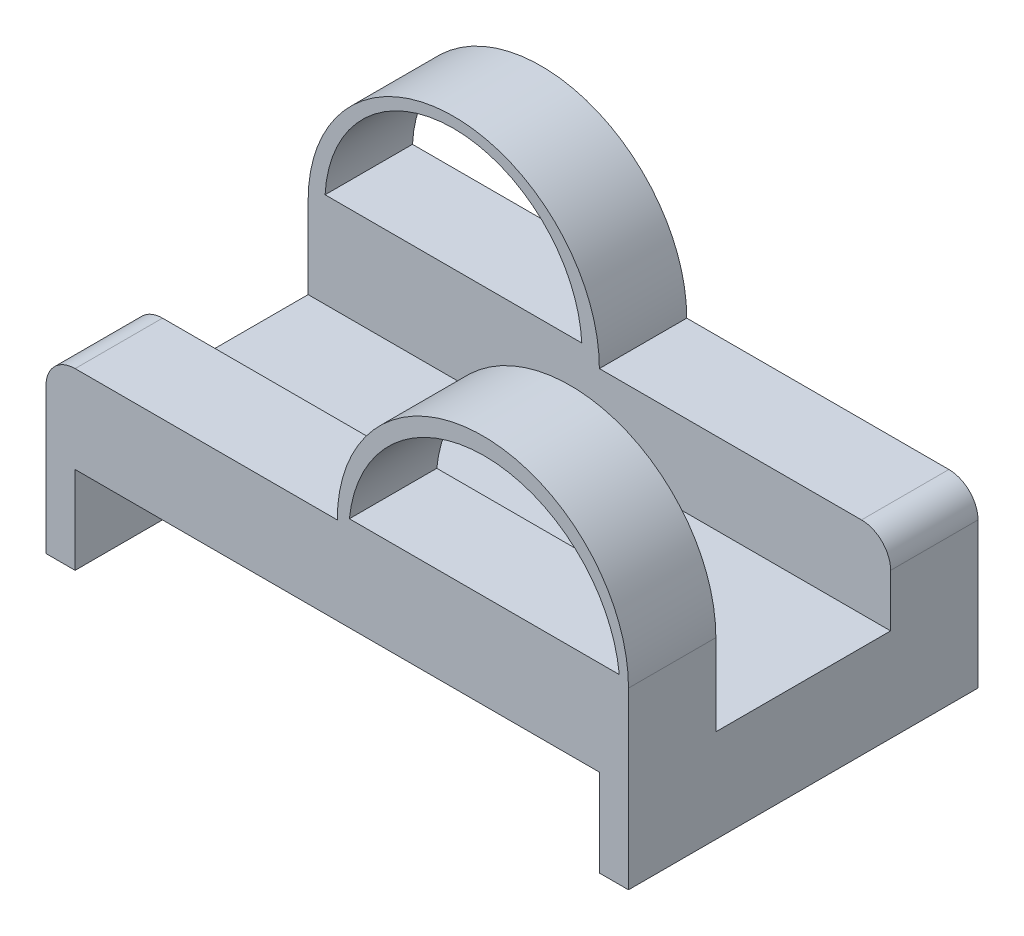
from build123d import *

# Parameters (mm, degrees)
BOSS_EXTRUDE1_DEPTH  = 60
BOSS_EXTRUDE2_DEPTH  = 15
BOSS_EXTRUDE4_DEPTH  = 15
CUT_EXTRUDE3_DEPTH   = 25
CUT_EXTRUDE4_DEPTH   = 25
FILLET2_R            = 5
FILLET3_R            = 5
SKETCH10_W           = 100
SKETCH10_H           = 30
CUT_EXTRUDE8_DEPTH   = 15
SKETCH12_W           = 100
SKETCH12_H           = 30
BOSS_EXTRUDE10_DEPTH = 1


with BuildPart() as part:
    # Sketch1 → Boss-Extrude1 (new body)
    with BuildSketch(Plane.XY):
        Polygon((-74.571428571, -3.428571429), (-74.571428571, 11.571428571), (15.428571429, 11.571428571), (15.428571429, -3.428571429), (20.428571429, -3.428571429), (20.428571429, 26.571428571), (-79.571428571, 26.571428571), (-79.571428571, -3.428571429), align=None)
    extrude(amount=-BOSS_EXTRUDE1_DEPTH)

    # Sketch3 → Boss-Extrude2 (add)
    with BuildSketch(Plane(origin=(0, 0, -60), x_dir=(-1, 0, 0), z_dir=(0, 0, -1))):
        with BuildLine():
            Line((29.571428571, 26.571428571), (79.571428571, 26.571428571))
            ThreePointArc((79.571428571, 26.571428571), (54.571428571, 51.571428571), (29.571428571, 26.571428571))
        make_face()
    extrude(amount=-BOSS_EXTRUDE2_DEPTH)

    # Sketch4 → Boss-Extrude4 (add)
    with BuildSketch(Plane.XY):
        with BuildLine():
            Line((20.428571429, 26.571428571), (-29.571428571, 26.571428571))
            ThreePointArc((-29.571428571, 26.571428571), (-4.571428571, 51.571428571), (20.428571429, 26.571428571))
        make_face()
    extrude(amount=-BOSS_EXTRUDE4_DEPTH)

    # Sketch5 → Cut-Extrude3 (cut)
    with BuildSketch(Plane.XY):
        with BuildLine():
            Line((-27.48668728, 27.787723549), (18.843123445, 27.787723549))
            ThreePointArc((18.843123445, 27.787723549), (-4.321781917, 48.729240211), (-27.48668728, 27.787723549))
        make_face()
    extrude(amount=-CUT_EXTRUDE3_DEPTH, mode=Mode.SUBTRACT)

    # Sketch6 → Cut-Extrude4 (cut)
    with BuildSketch(Plane.XY.offset(-45)):
        with BuildLine():
            Line((-76.657542496, 28.868881688), (-32.592047201, 28.868881688))
            ThreePointArc((-32.592047201, 28.868881688), (-54.624794848, 49.768229308), (-76.657542496, 28.868881688))
        make_face()
    extrude(amount=-CUT_EXTRUDE4_DEPTH, mode=Mode.SUBTRACT)

    # Fillet2
    fillet2_edges = [part.edges().sort_by_distance(p)[0] for p in [
        (-79.571428571, 26.571428571, -22.5),
    ]]
    fillet(fillet2_edges, radius=FILLET2_R)

    # Fillet3
    fillet3_edges = [part.edges().sort_by_distance(p)[0] for p in [
        (20.428571429, 26.571428571, -37.5),
    ]]
    fillet(fillet3_edges, radius=FILLET3_R)

    # Sketch10 → Cut-Extrude8 (cut)
    with BuildSketch(Plane(origin=(0, 26.571428571, 0), x_dir=(1, 0, 0), z_dir=(0, 1, 0))):
        with Locations((-29.571428571, 30)):
            Rectangle(SKETCH10_W, SKETCH10_H)
    extrude(amount=-CUT_EXTRUDE8_DEPTH, mode=Mode.SUBTRACT)

    # Sketch12 → Boss-Extrude10 (add)
    with BuildSketch(Plane(origin=(0, 11.571428571, 0), x_dir=(1, 0, 0), z_dir=(0, 1, 0))):
        with Locations((-29.571428571, 30)):
            Rectangle(SKETCH12_W, SKETCH12_H)
    extrude(amount=BOSS_EXTRUDE10_DEPTH)


solid = part.part
